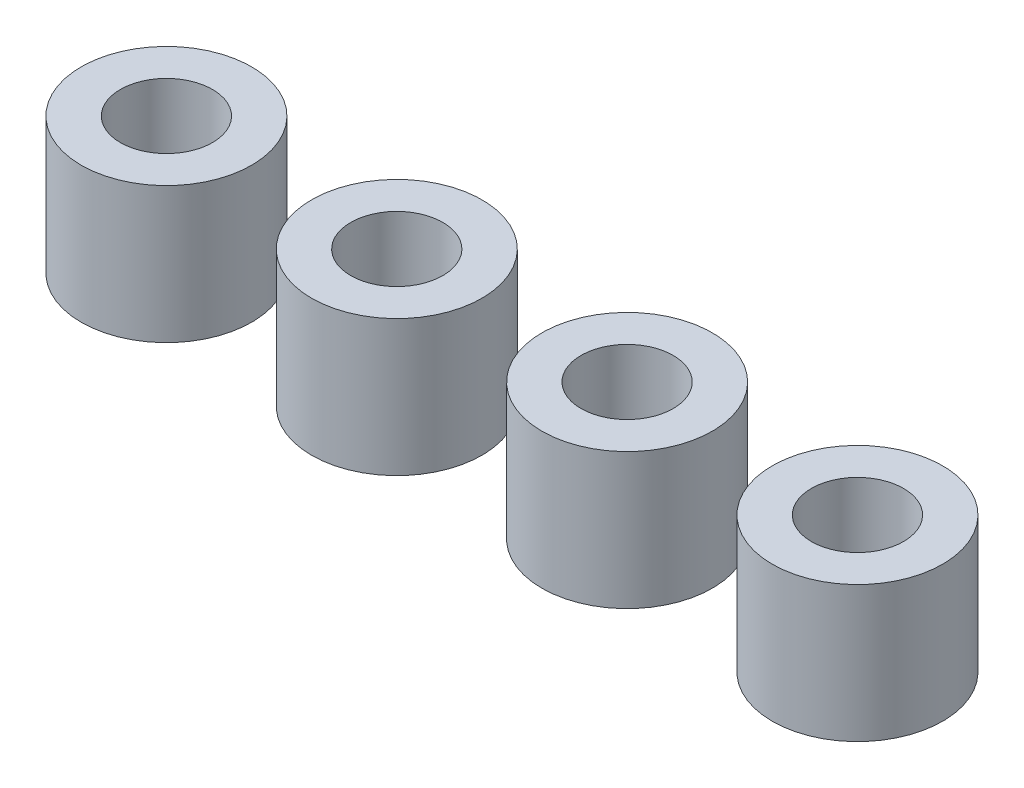
from build123d import *

# Parameters (mm, degrees)
SKETCH1_R             = 0.94
SKETCH1_R_2           = 0.508
BOSS_EXTRUDE1_DEPTH   = 1.5
BOSS_EXTRUDE1_2_DEPTH = 1.5
BOSS_EXTRUDE1_3_DEPTH = 1.5
BOSS_EXTRUDE1_4_DEPTH = 1.5


with BuildPart() as part:
    # Sketch1 → Boss-Extrude1 (new body)
    with BuildSketch(Plane(origin=(0, 0, 0), x_dir=(1, 0, 0), z_dir=(0, 1, 0))):
        with Locations((-2.815110191, 1.681457709)):
            Circle(SKETCH1_R)
        with Locations((-2.815110191, 1.681457709)):
            Circle(SKETCH1_R_2, mode=Mode.SUBTRACT)
    extrude(amount=BOSS_EXTRUDE1_DEPTH)


with BuildPart() as body_2:
    # Sketch1 → Boss-Extrude1 2 (new body)
    with BuildSketch(Plane(origin=(0, 0, 0), x_dir=(1, 0, 0), z_dir=(0, 1, 0))):
        with Locations((-0.275110191, 1.681457709)):
            Circle(SKETCH1_R)
        with Locations((-0.275110191, 1.681457709)):
            Circle(SKETCH1_R_2, mode=Mode.SUBTRACT)
    extrude(amount=BOSS_EXTRUDE1_2_DEPTH)


with BuildPart() as body_3:
    # Sketch1 → Boss-Extrude1 3 (new body)
    with BuildSketch(Plane(origin=(0, 0, 0), x_dir=(1, 0, 0), z_dir=(0, 1, 0))):
        with Locations((2.264889809, 1.681457709)):
            Circle(SKETCH1_R)
        with Locations((2.264889809, 1.681457709)):
            Circle(SKETCH1_R_2, mode=Mode.SUBTRACT)
    extrude(amount=BOSS_EXTRUDE1_3_DEPTH)


with BuildPart() as body_4:
    # Sketch1 → Boss-Extrude1 4 (new body)
    with BuildSketch(Plane(origin=(0, 0, 0), x_dir=(1, 0, 0), z_dir=(0, 1, 0))):
        with Locations((4.804889809, 1.681457709)):
            Circle(SKETCH1_R)
        with Locations((4.804889809, 1.681457709)):
            Circle(SKETCH1_R_2, mode=Mode.SUBTRACT)
    extrude(amount=BOSS_EXTRUDE1_4_DEPTH)


solid = Compound([part.part, body_2.part, body_3.part, body_4.part])
